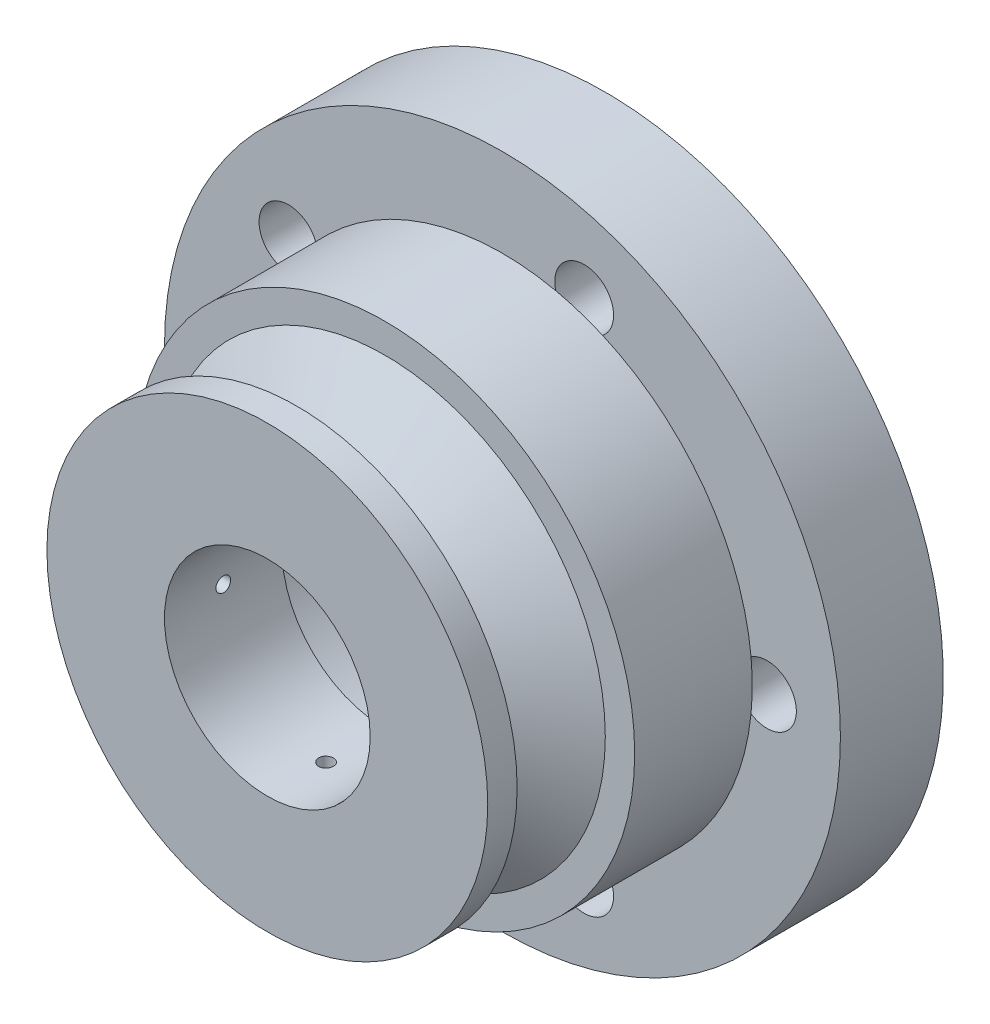
from build123d import *

# Parameters (mm, degrees)
SKETCH_1_R          = 11.5
SKETCH_1_R_2        = 1
SKETCH_1_R_3        = 6
EXTRUDE_1_DEPTH     = 2.5
SKETCH_2_R          = 8.5
SKETCH_2_R_2        = 6
EXTRUDE_2_DEPTH     = 4
SKETCH_3_R          = 7.5
EXTRUDE_3_DEPTH     = 4
SKETCH_4_R          = 3.5
CUT_EXTRUDE_1_DEPTH = 4
SKETCH_6_R          = 0.25
CUT_EXTRUDE_2_DEPTH = 14
SKETCH_7_R          = 11.5
SKETCH_7_R_2        = 1
SKETCH_7_R_3        = 6
EXTRUDE_4_DEPTH     = 1
SKETCH_9_R          = 0.25
CUT_EXTRUDE_8_DEPTH = 12.2


with BuildPart() as part:
    # 草图1 → 凸台-拉伸1 (new body)
    with BuildSketch(Plane.XY):
        Circle(SKETCH_1_R)
        with Locations((9, 0)):
            Circle(SKETCH_1_R_2, mode=Mode.SUBTRACT)
        with Locations((2.781152949, -8.559508647)):
            Circle(SKETCH_1_R_2, mode=Mode.SUBTRACT)
        with Locations((-7.281152949, -5.290067271)):
            Circle(SKETCH_1_R_2, mode=Mode.SUBTRACT)
        with Locations((-7.281152949, 5.290067271)):
            Circle(SKETCH_1_R_2, mode=Mode.SUBTRACT)
        with Locations((2.781152949, 8.559508647)):
            Circle(SKETCH_1_R_2, mode=Mode.SUBTRACT)
        Circle(SKETCH_1_R_3, mode=Mode.SUBTRACT)
    extrude(amount=EXTRUDE_1_DEPTH)

    # 草图2 → 凸台-拉伸2 (add)
    with BuildSketch(Plane.XY.offset(2.5)):
        Circle(SKETCH_2_R)
        Circle(SKETCH_2_R_2, mode=Mode.SUBTRACT)
    extrude(amount=EXTRUDE_2_DEPTH)

    # 草图3 → 凸台-拉伸3 (add)
    with BuildSketch(Plane.XY.offset(6.5)):
        Circle(SKETCH_3_R)
    extrude(amount=EXTRUDE_3_DEPTH)

    # 草图4 → 切除-拉伸1 (cut)
    with BuildSketch(Plane.XY.offset(10.5)):
        Circle(SKETCH_4_R)
    extrude(amount=-CUT_EXTRUDE_1_DEPTH, mode=Mode.SUBTRACT)

    # 草图5 → 切除-旋转2 (revolve, cut)
    with BuildSketch(Plane(origin=(0, 0, 0), x_dir=(0, 0, -1), z_dir=(1, 0, 0))):
        Polygon((-7.5, 7.5), (-9.5, 7.5), (-8.75, 4.5), (-8.25, 4.5), (-6.5, 7.5), align=None)
    revolve(axis=Axis((0, 0, 10.5), (0, 0, -1)), mode=Mode.SUBTRACT)

    # 草图6 → 切除-拉伸2 (cut)
    with BuildSketch(Plane(origin=(0, 0, 0), x_dir=(1, 0, 0), z_dir=(0, 1, 0))):
        with Locations((0, -8.5)):
            Circle(SKETCH_6_R)
    extrude(amount=-CUT_EXTRUDE_2_DEPTH, mode=Mode.SUBTRACT)

    # 草图7 → 凸台-拉伸4 (add)
    with BuildSketch(Plane(origin=(0, 0, 0), x_dir=(-1, 0, 0), z_dir=(0, 0, -1))):
        Circle(SKETCH_7_R)
        with Locations((-2.781152949, -8.559508647)):
            Circle(SKETCH_7_R_2, mode=Mode.SUBTRACT)
        with Locations((7.281152949, -5.290067271)):
            Circle(SKETCH_7_R_2, mode=Mode.SUBTRACT)
        with Locations((7.281152949, 5.290067271)):
            Circle(SKETCH_7_R_2, mode=Mode.SUBTRACT)
        with Locations((-2.781152949, 8.559508647)):
            Circle(SKETCH_7_R_2, mode=Mode.SUBTRACT)
        with Locations((-9, 0)):
            Circle(SKETCH_7_R_2, mode=Mode.SUBTRACT)
        Circle(SKETCH_7_R_3, mode=Mode.SUBTRACT)
    extrude(amount=EXTRUDE_4_DEPTH)

    # 草图9 → 切除-拉伸8 (cut)
    with BuildSketch(Plane(origin=(0, 0, 0), x_dir=(0, 0, -1), z_dir=(1, 0, 0))):
        with Locations((-8.5, 0)):
            Circle(SKETCH_9_R)
    extrude(amount=-CUT_EXTRUDE_8_DEPTH, mode=Mode.SUBTRACT)


solid = part.part
